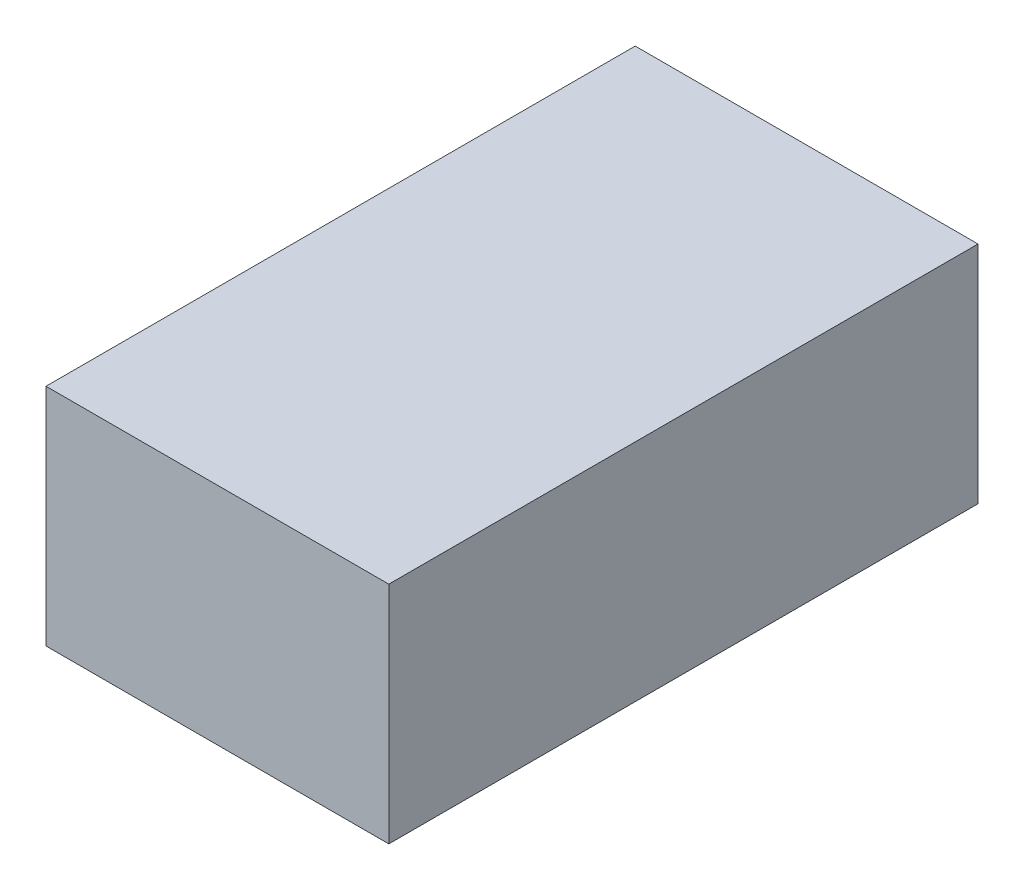
from build123d import *

# Parameters (mm, degrees)
SKETCH1_W           = 32
SKETCH1_H           = 55
BOSS_EXTRUDE1_DEPTH = 21


with BuildPart() as part:
    # Sketch1 → Boss-Extrude1 (new body)
    with BuildSketch(Plane(origin=(0, 0, 0), x_dir=(1, 0, 0), z_dir=(0, 1, 0))):
        Rectangle(SKETCH1_W, SKETCH1_H)
    extrude(amount=BOSS_EXTRUDE1_DEPTH)


solid = part.part
